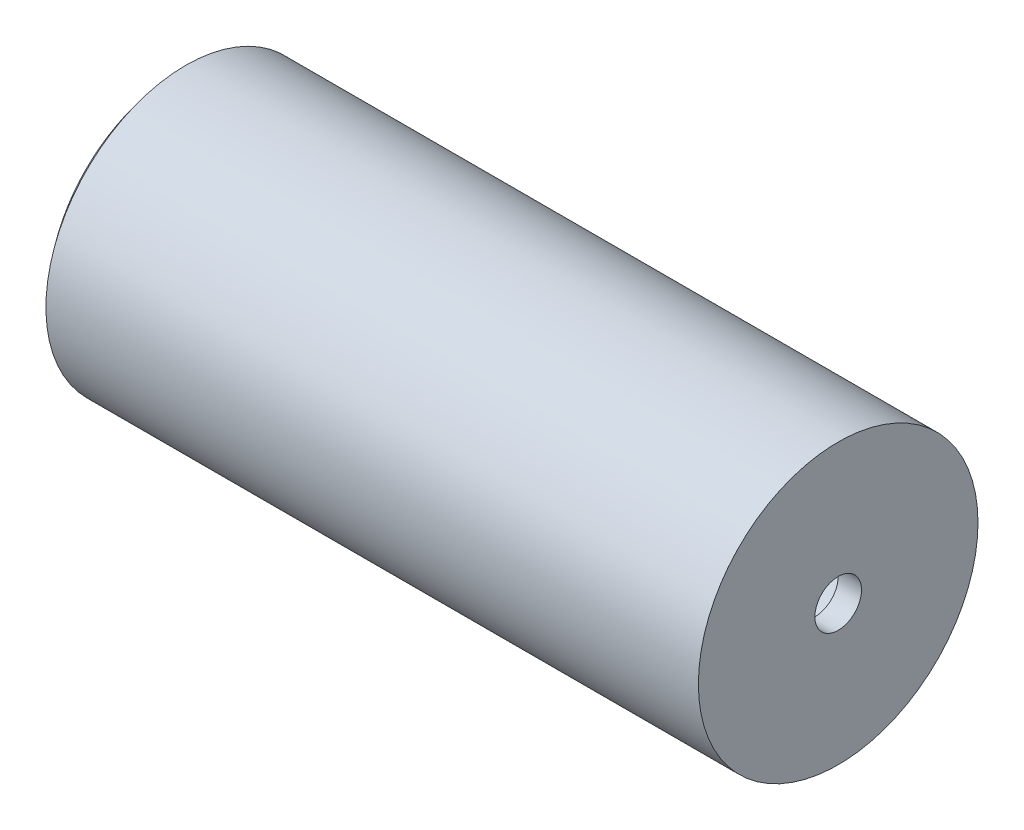
from build123d import *


with BuildPart() as part:
    # Sketch1 → Revolve6 (revolve)
    with BuildSketch(Plane.XY):
        with BuildLine():
            Line((169.943031877, 5), (169.943031877, 30))
            Line((169.943031877, 30), (29.943031877, 30))
            ThreePointArc((29.943031877, 30), (21.844861375, 15.961189352), (19.032566162, 0))
            Line((19.032566162, 0), (24.032566162, 0))
            ThreePointArc((24.032566162, 0), (26.168520101, 13.174839994), (32.357566788, 25))
            Line((32.357566788, 25), (164.943031877, 25))
            Line((164.943031877, 25), (164.943031877, 5))
            Line((164.943031877, 5), (169.943031877, 5))
        make_face()
    revolve(axis=Axis((0, 0, 0), (-1, 0, 0)))


solid = part.part
